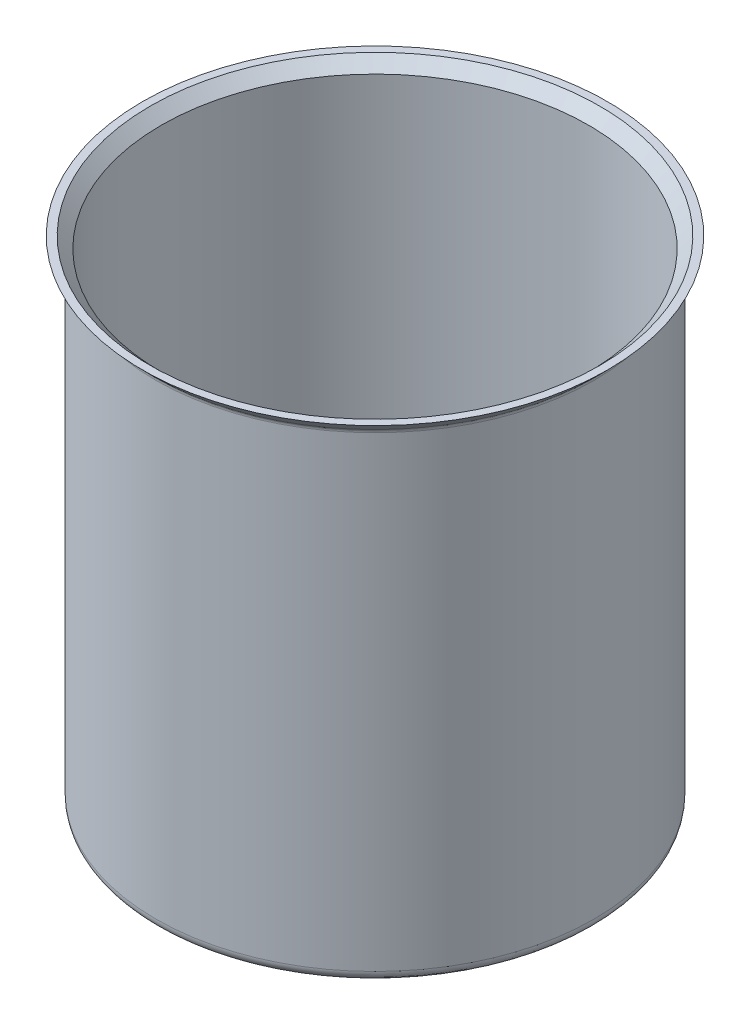
from build123d import *

# Parameters (mm, degrees)
SHELL2_T  = -1
FILLET1_R = 2
FILLET2_R = 1


with BuildPart() as part:
    # Sketch1 → Revolve1 (revolve)
    with BuildSketch(Plane.XY, mode=Mode.PRIVATE) as revolve1_sk:
        Polygon((0, -38.642009768), (40, -38.642009768), (40, 48.926842765), (42.431147467, 51.357990232), (0, 51.357990232), align=None)
    revolve(revolve1_sk.sketch.rotate(Axis((0, 51.357990232, 0), (0, -1, 0)), 180), axis=Axis((0, 51.357990232, 0), (0, -1, 0)))

    # Shell2
    shell2_openings = [part.faces().sort_by_distance(p)[0] for p in [
        (0, 51.357990232, 0),
    ]]
    offset(amount=SHELL2_T, openings=shell2_openings, kind=Kind.INTERSECTION)

    # Fillet1
    fillet1_edges = [part.edges().sort_by_distance(p)[0] for p in [
        (40, -38.642009768, 0),
    ]]
    fillet(fillet1_edges, radius=FILLET1_R)

    # Fillet2
    fillet2_edges = [part.edges().sort_by_distance(p)[0] for p in [
        (40, 48.926842765, 0),
    ]]
    fillet(fillet2_edges, radius=FILLET2_R)


solid = part.part
